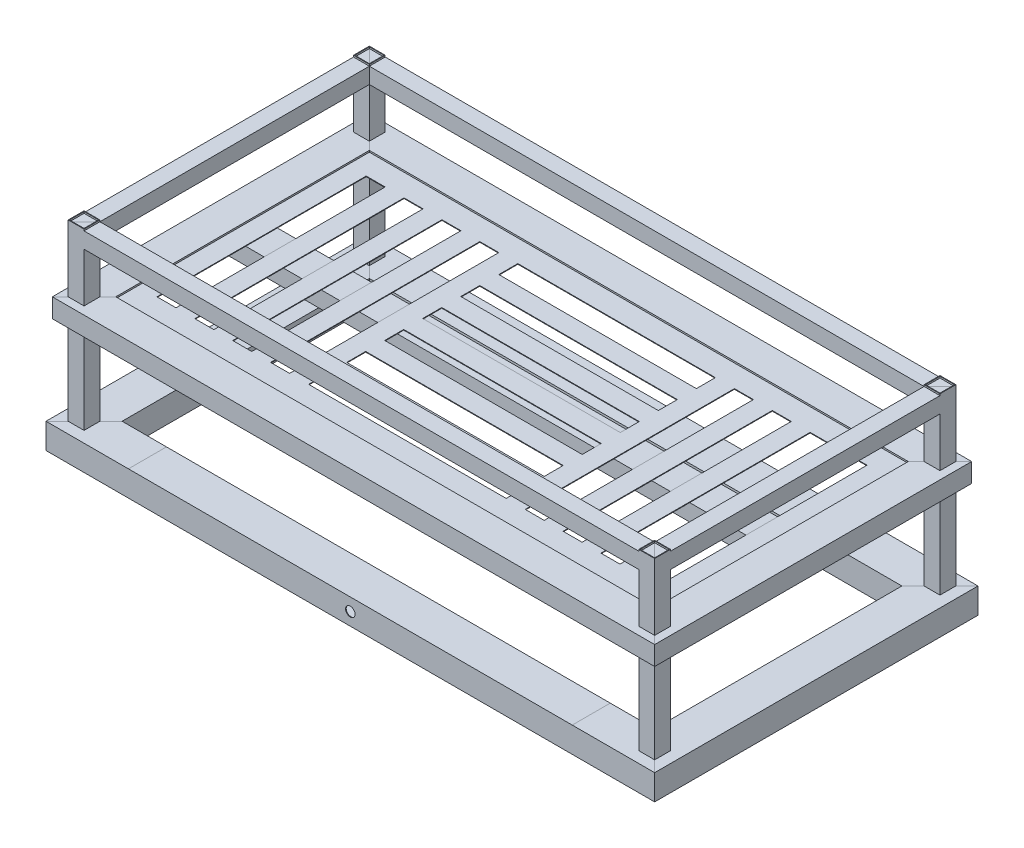
from build123d import *

# Parameters (mm, degrees)
SKETCH2_W           = 116
SKETCH2_H           = 76
SKETCH3_W           = 50
SKETCH3_H           = 50
SKETCH3_W_2         = 46
SKETCH3_H_2         = 46
BOSS_EXTRUDE1_DEPTH = 550
BOSS_EXTRUDE3_START = -5
SKETCH6_W           = 1700
SKETCH6_H           = 800
BOSS_EXTRUDE3_DEPTH = 2
SKETCH7_W           = 60
SKETCH7_H           = 660
SKETCH7_W_2         = 623.131922332
SKETCH7_H_2         = 60
CUT_EXTRUDE1_DEPTH  = 127
BOSS_EXTRUDE4_REACH = 1972.863
SKETCH11_W          = 100
SKETCH11_H          = 53
SKETCH11_W_2        = 96
SKETCH11_H_2        = 49
SKETCH14_W          = 120
SKETCH14_H          = 80
SKETCH14_W_2        = 116
SKETCH14_H_2        = 76
BOSS_EXTRUDE5_DEPTH = 1400.000002
SKETCH15_R          = 15
CUT_EXTRUDE2_DEPTH  = 5


with BuildPart() as part:
    # Sweep2: sweep along a path in Sketch1
    with BuildLine(Plane(origin=(0, 0, 0), x_dir=(1, 0, 0), z_dir=(0, 1, 0))) as sweep2_path:
        Line((-700, -450), (-900, -450))
        Line((-900, -450), (-900, 450))
        Line((-900, 450), (900, 450))
        Line((900, 450), (900, -450))
        Line((900, -450), (700, -450))
    # 3DSketch2 → Sweep2 (sweep)
    with BuildSketch(Plane(origin=(-700.000003607, -40, 510), x_dir=(5.002125996621037e-08, 0.5547001962252266, -0.8320502943378439), z_dir=(0.999999999999996, -9.017710883574281e-08, 0))):
        Polygon((0, 0), (44.376015698, 66.564023547), (144.222051019, 0), (99.846035321, -66.564023547), align=None)
    sweep(path=sweep2_path.line, transition=Transition.RIGHT)

    # Cut-Sweep1: sweep along a path in Sketch1_3
    with BuildLine(Plane(origin=(0, 0, 0), x_dir=(1, 0, 0), z_dir=(0, 1, 0))) as cut_sweep1_path:
        Line((-700, -450), (-900, -450))
        Line((-900, -450), (-900, 450))
        Line((-900, 450), (900, 450))
        Line((900, 450), (900, -450))
        Line((900, -450), (700, -450))
    # Sketch2 → Cut-Sweep1 (sweep, cut)
    with BuildSketch(Plane(origin=(-700, 6.3124e-05, 0), x_dir=(0, 0, -1), z_dir=(0.999999999999996, -9.017710883574252e-08, 0))):
        with Locations((-450, 8.657e-05)):
            Rectangle(SKETCH2_W, SKETCH2_H)
    sweep(path=cut_sweep1_path.line, transition=Transition.RIGHT, mode=Mode.SUBTRACT)

    # Sketch3 → Boss-Extrude1 (add)
    with BuildSketch(Plane(origin=(0, 40, 0), x_dir=(1, 0, 0), z_dir=(0, 1, 0))):
        with Locations((900, -450)):
            Rectangle(SKETCH3_W, SKETCH3_H)
        with Locations((900, -450)):
            Rectangle(SKETCH3_W_2, SKETCH3_H_2, mode=Mode.SUBTRACT)
        with Locations((900, 450)):
            Rectangle(SKETCH3_W, SKETCH3_H)
        with Locations((900, 450)):
            Rectangle(SKETCH3_W_2, SKETCH3_H_2, mode=Mode.SUBTRACT)
        with Locations((-900, 450)):
            Rectangle(SKETCH3_W, SKETCH3_H)
        with Locations((-900, 450)):
            Rectangle(SKETCH3_W_2, SKETCH3_H_2, mode=Mode.SUBTRACT)
        with Locations((-900, -450)):
            Rectangle(SKETCH3_W, SKETCH3_H)
        with Locations((-900, -450)):
            Rectangle(SKETCH3_W_2, SKETCH3_H_2, mode=Mode.SUBTRACT)
    extrude(amount=BOSS_EXTRUDE1_DEPTH)

    # Sweep4: sweep along a path in Sketch4
    with BuildLine(Plane(origin=(0, 560, 0), x_dir=(1, 0, 0), z_dir=(0, 1, 0))) as sweep4_path:
        Line((900, 450), (-900, 450))
        Line((-900, 450), (-900, -450))
        Line((-900, -450), (900, -450))
        Line((900, -450), (900, 450))
    # 3DSketch3 → Sweep4 (sweep)
    with BuildSketch(Plane(origin=(-875, 585, 450), x_dir=(-0.7071067811865476, -0.7071067811865476, 0), z_dir=(0, 0, -1))):
        Polygon((0, 0), (35.355339059, 35.355339059), (70.710678119, 0), (35.355339059, -35.355339059), align=None)
    sweep(path=sweep4_path.line, transition=Transition.RIGHT)

    # Cut-Sweep2: sweep along a path in Sketch4_2
    with BuildLine(Plane(origin=(0, 560, 0), x_dir=(1, 0, 0), z_dir=(0, 1, 0))) as cut_sweep2_path:
        Line((900, 450), (-900, 450))
        Line((-900, 450), (-900, -450))
        Line((-900, -450), (900, -450))
        Line((900, -450), (900, 450))
    # 3DSketch4 → Cut-Sweep2 (sweep, cut)
    with BuildSketch(Plane(origin=(-877, 583, 450), x_dir=(-0.7071067811865476, -0.7071067811865476, 0), z_dir=(0, 0, -1))):
        Polygon((0, 0), (32.526911935, 32.526911935), (65.053823869, 0), (32.526911935, -32.526911935), align=None)
    sweep(path=cut_sweep2_path.line, transition=Transition.RIGHT, mode=Mode.SUBTRACT)

    # Sweep5: sweep along a path in Sketch5
    with BuildLine(Plane(origin=(0, 350, 0), x_dir=(1, 0, 0), z_dir=(0, 1, 0))) as sweep5_path:
        Line((900, 450), (-900, 450))
        Line((-900, 450), (-900, -450))
        Line((-900, -450), (900, -450))
        Line((900, -450), (900, 450))
    # 3DSketch5 → Sweep5 (sweep)
    with BuildSketch(Plane(origin=(-850, 380, 450), x_dir=(-0.8574929257125442, -0.5144957554275267, 0), z_dir=(0, 0, -1))):
        Polygon((0, 0), (85.749292571, 51.449575543), (116.619037897, 0), (30.869745326, -51.449575543), align=None)
    sweep(path=sweep5_path.line, transition=Transition.RIGHT)

    # Cut-Sweep3: sweep along a path in Sketch5_2
    with BuildLine(Plane(origin=(0, 350, 0), x_dir=(1, 0, 0), z_dir=(0, 1, 0))) as cut_sweep3_path:
        Line((900, 450), (-900, 450))
        Line((-900, 450), (-900, -450))
        Line((-900, -450), (900, -450))
        Line((900, -450), (900, 450))
    # 3DSketch6 → Cut-Sweep3 (sweep, cut)
    with BuildSketch(Plane(origin=(-852, 378, 450), x_dir=(-0.8637789008984333, -0.5038710255240862, 0), z_dir=(0, 0, 1))):
        Polygon((0, 0), (82.922774486, -48.37161845), (111.139551916, 0), (28.216777429, 48.37161845), align=None)
    sweep(path=cut_sweep3_path.line, transition=Transition.RIGHT, mode=Mode.SUBTRACT)

    # Sketch6 → Boss-Extrude3 (add)
    with BuildSketch(Plane(origin=(0, 380, 0), x_dir=(1, 0, 0), z_dir=(0, 1, 0)).offset(BOSS_EXTRUDE3_START)):
        Rectangle(SKETCH6_W, SKETCH6_H)
    extrude(amount=-BOSS_EXTRUDE3_DEPTH)

    # Sketch7 → Cut-Extrude1 (cut)
    with BuildSketch(Plane(origin=(0, 375, 0), x_dir=(1, 0, 0), z_dir=(0, 1, 0))):
        with Locations((-760, 0)):
            Rectangle(SKETCH7_W, SKETCH7_H)
        with Locations((-640.521987055, 0)):
            Rectangle(SKETCH7_W, SKETCH7_H)
        with Locations((-521.043974111, 0)):
            Rectangle(SKETCH7_W, SKETCH7_H)
        with Locations((-401.565961166, 0)):
            Rectangle(SKETCH7_W, SKETCH7_H)
        with Locations((760, 0)):
            Rectangle(SKETCH7_W, SKETCH7_H)
        with Locations((640.521987055, 0)):
            Rectangle(SKETCH7_W, SKETCH7_H)
        with Locations((521.043974111, 0)):
            Rectangle(SKETCH7_W, SKETCH7_H)
        with Locations((401.565961166, 0)):
            Rectangle(SKETCH7_W, SKETCH7_H)
        with Locations((0, 300)):
            Rectangle(SKETCH7_W_2, SKETCH7_H_2)
        with Locations((0, 180)):
            Rectangle(SKETCH7_W_2, SKETCH7_H_2)
        with Locations((0, 60)):
            Rectangle(SKETCH7_W_2, SKETCH7_H_2)
        with Locations((0, -60)):
            Rectangle(SKETCH7_W_2, SKETCH7_H_2)
        with Locations((0, -180)):
            Rectangle(SKETCH7_W_2, SKETCH7_H_2)
        with Locations((0, -300)):
            Rectangle(SKETCH7_W_2, SKETCH7_H_2)
    extrude(amount=-CUT_EXTRUDE1_DEPTH, mode=Mode.SUBTRACT)

    # Sketch11 → Boss-Extrude4 (add, up to next)
    with BuildSketch(Plane.ZY.offset(-850), mode=Mode.PRIVATE) as boss_extrude4_sk1:
        with Locations((0, 346.5)):
            Rectangle(SKETCH11_W, SKETCH11_H)
        with Locations((0, 346.5)):
            Rectangle(SKETCH11_W_2, SKETCH11_H_2, mode=Mode.SUBTRACT)
    boss_extrude4_tool1 = extrude(boss_extrude4_sk1.sketch, amount=BOSS_EXTRUDE4_REACH, mode=Mode.PRIVATE) - part.part
    add(boss_extrude4_tool1.solids().sort_by_distance((850, 321.131769, 0))[0])

    # Sketch14 → Boss-Extrude5 (add)
    with BuildSketch(Plane(origin=(-700, 6.3124e-05, 0), x_dir=(0, 0, -1), z_dir=(0.9999999999999959, -9.017710883574281e-08, 0))):
        with Locations((-450, -6.3124e-05)):
            Rectangle(SKETCH14_W, SKETCH14_H)
        with Locations((-450, 8.657e-05)):
            Rectangle(SKETCH14_W_2, SKETCH14_H_2, mode=Mode.SUBTRACT)
    extrude(amount=BOSS_EXTRUDE5_DEPTH)

    # Sketch15 → Cut-Extrude2 (cut)
    with BuildSketch(Plane.XY.offset(510)):
        Circle(SKETCH15_R)
    extrude(amount=-CUT_EXTRUDE2_DEPTH, mode=Mode.SUBTRACT)


solid = part.part
